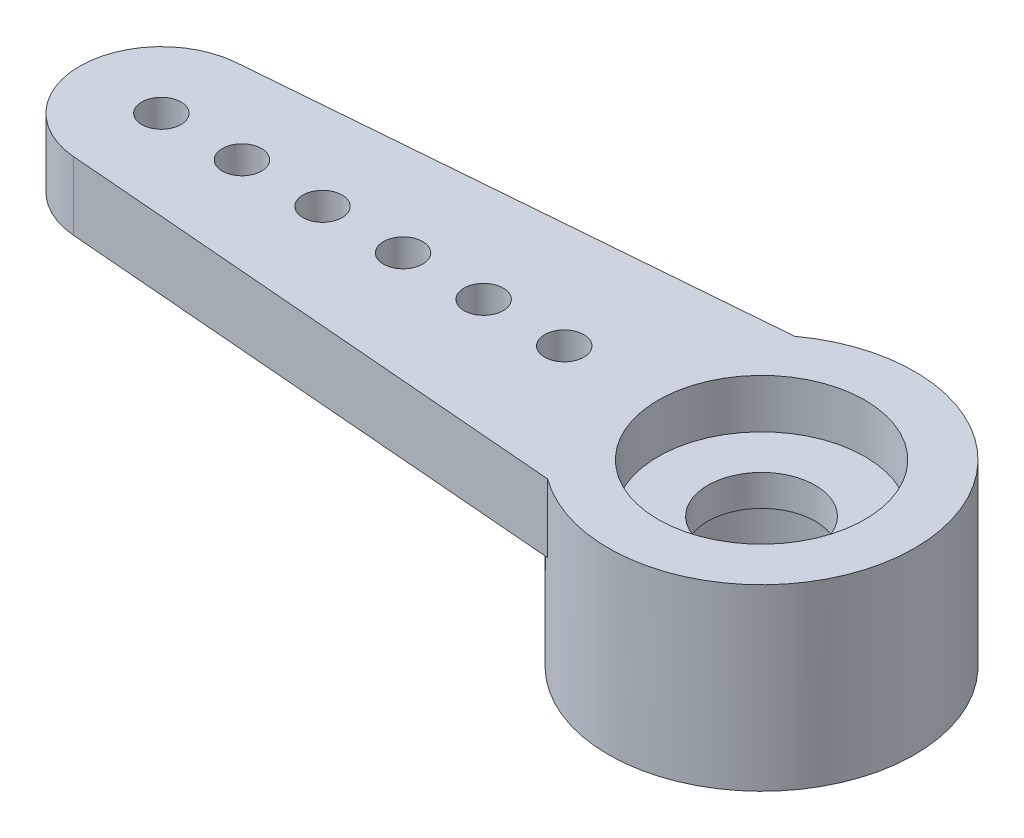
from build123d import *

# Parameters (mm, degrees)
EXTRUDE17_DEPTH = 1.6129
SKETCH19_R      = 3.6195
EXTRUDE19_DEPTH = 4.2291
SKETCH20_R      = 0.46355
SKETCH20_R_2    = 1.27
EXTRUDE20_DEPTH = 5.2291
SKETCH21_R      = 2.44475
EXTRUDE21_DEPTH = 1.1557
SKETCH22_R      = 2.286
EXTRUDE22_DEPTH = 2.3368


with BuildPart() as part:
    # Sketch18 → Extrude17 (new body)
    with BuildSketch(Plane(origin=(0, 0, 0), x_dir=(1, 0, 0), z_dir=(0, 1, 0))):
        with BuildLine():
            Line((-14.347205988, 1.923996328), (-2.13741415, 2.921))
            ThreePointArc((-2.13741415, 2.921), (3.6195, 0), (-2.13741415, -2.921))
            Line((-2.13741415, -2.921), (-14.347205988, -1.923996328))
            ThreePointArc((-14.347205988, -1.923996328), (-16.1205, 0), (-14.347205988, 1.923996328))
        make_face()
    extrude(amount=EXTRUDE17_DEPTH)

    # Sketch19 → Extrude19 (add)
    with BuildSketch(Plane(origin=(0, 1.6129, 0), x_dir=(1, 0, 0), z_dir=(0, 1, 0))):
        Circle(SKETCH19_R)
    extrude(amount=-EXTRUDE19_DEPTH)

    # Sketch20 → Extrude20 (cut, through all)
    with BuildSketch(Plane(origin=(0, 1.6129, 0), x_dir=(1, 0, 0), z_dir=(0, 1, 0))):
        with Locations((-14.1901, 0)):
            Circle(SKETCH20_R)
        Circle(SKETCH20_R_2)
        with Locations((-4.6651, 0)):
            Circle(SKETCH20_R)
        with Locations((-6.5701, 0)):
            Circle(SKETCH20_R)
        with Locations((-8.4751, 0)):
            Circle(SKETCH20_R)
        with Locations((-10.3801, 0)):
            Circle(SKETCH20_R)
        with Locations((-12.2851, 0)):
            Circle(SKETCH20_R)
    extrude(amount=-EXTRUDE20_DEPTH, mode=Mode.SUBTRACT)

    # Sketch21 → Extrude21 (cut)
    with BuildSketch(Plane(origin=(0, 1.6129, 0), x_dir=(1, 0, 0), z_dir=(0, 1, 0))):
        Circle(SKETCH21_R)
    extrude(amount=-EXTRUDE21_DEPTH, mode=Mode.SUBTRACT)

    # Sketch22 → Extrude22 (cut)
    with BuildSketch(Plane.XZ.offset(2.6162)):
        Circle(SKETCH22_R)
    extrude(amount=-EXTRUDE22_DEPTH, mode=Mode.SUBTRACT)


solid = part.part
